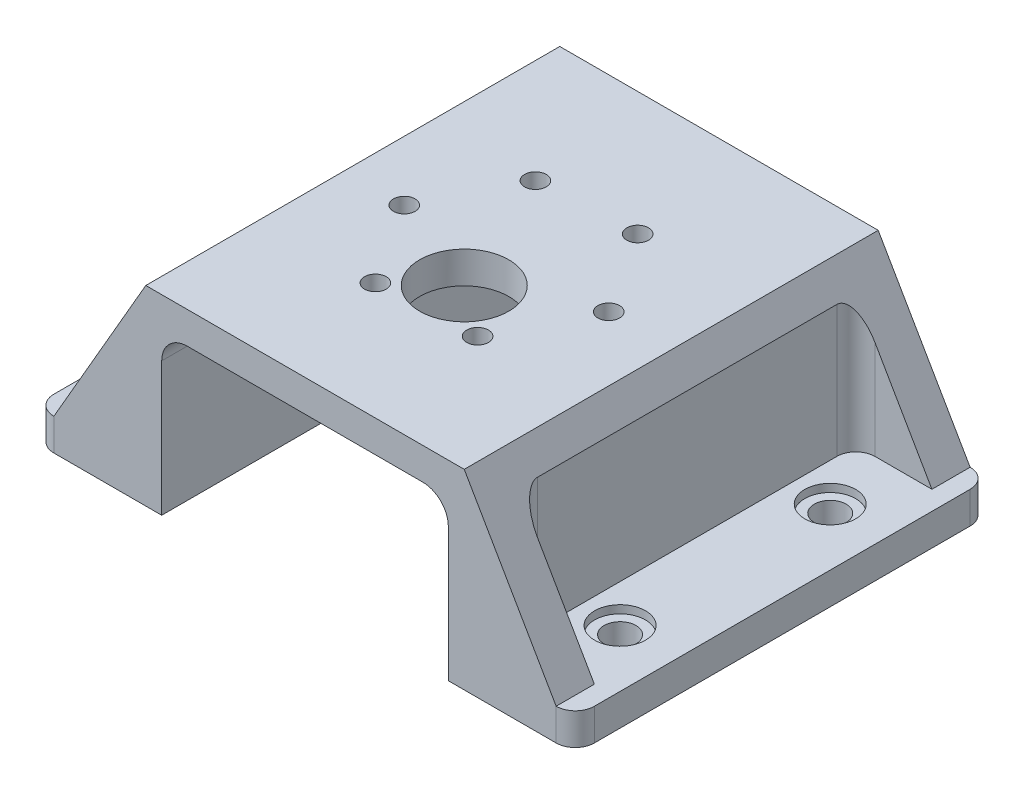
from build123d import *

# Parameters (mm, degrees)
SKETCH1_W           = 50
SKETCH1_H           = 50
BOSS_EXTRUDE1_DEPTH = 30
SKETCH2_R           = 7
CUT_EXTRUDE1_DEPTH  = 30
SKETCH3_R           = 1.7
CUT_EXTRUDE2_DEPTH  = 42
SKETCH5_W           = 50
SKETCH5_H           = 15
BOSS_EXTRUDE2_DEPTH = 30
BOSS_EXTRUDE3_DEPTH = 65
SKETCH7_W           = 45
SKETCH7_H           = 42.253035939
CUT_EXTRUDE3_DEPTH  = 66
FILLET1_R           = 4
CUT_EXTRUDE4_DEPTH  = 53
SKETCH10_R          = 4
CUT_EXTRUDE5_DEPTH  = 1.25
SKETCH11_R          = 2.5
CUT_EXTRUDE6_DEPTH  = 36.25
CUT_EXTRUDE7_DEPTH  = 90.25
FILLET2_R           = 3
SKETCH13_W          = 3
SKETCH13_H          = 5
BOSS_EXTRUDE4_DEPTH = 65
FILLET3_R           = 3


with BuildPart() as part:
    # Sketch1 → Boss-Extrude1 (new body)
    with BuildSketch(Plane(origin=(0, 0, 0), x_dir=(1, 0, 0), z_dir=(0, 1, 0))):
        Rectangle(SKETCH1_W, SKETCH1_H)
    extrude(amount=BOSS_EXTRUDE1_DEPTH)

    # Sketch2 → Cut-Extrude1 (cut)
    with BuildSketch(Plane(origin=(0, 30, 0), x_dir=(1, 0, 0), z_dir=(0, 1, 0))):
        Circle(SKETCH2_R)
    extrude(amount=-CUT_EXTRUDE1_DEPTH, mode=Mode.SUBTRACT)

    # Sketch3 → Cut-Extrude2 (cut)
    with BuildSketch(Plane.XZ):
        with Locations((6.617670641, -20.610654448)):
            Circle(SKETCH3_R)
        with Locations((14.927003033, -7.763670553)):
            Circle(SKETCH3_R)
        with Locations((7.955854814, 5.855914334)):
            Circle(SKETCH3_R)
        with Locations((-7.324625797, 6.628515327)):
            Circle(SKETCH3_R)
        with Locations((-15.633958189, -6.218468568)):
            Circle(SKETCH3_R)
        with Locations((-8.66280997, -19.838053456)):
            Circle(SKETCH3_R)
    extrude(amount=-CUT_EXTRUDE2_DEPTH, mode=Mode.SUBTRACT)

    # Sketch5 → Boss-Extrude2 (add)
    with BuildSketch(Plane(origin=(0, 30, 0), x_dir=(1, 0, 0), z_dir=(0, 1, 0))):
        with Locations((0, 32.5)):
            Rectangle(SKETCH5_W, SKETCH5_H)
    extrude(amount=-BOSS_EXTRUDE2_DEPTH)

    # Sketch6 → Boss-Extrude3 (add)
    with BuildSketch(Plane.XY.offset(25)):
        Polygon((-25, 30), (-42.320508076, 0), (-25, 0), align=None)
    boss_extrude3 = extrude(amount=-BOSS_EXTRUDE3_DEPTH)

    # Mirror1: Boss-Extrude3 across plane
    add(boss_extrude3.mirror(Plane(origin=(0, 0, 0), x_dir=(0, 0, 1), z_dir=(1, 0, 0))))

    # Sketch7 → Cut-Extrude3 (cut)
    with BuildSketch(Plane.XY.offset(25)):
        with Locations((0, 3.87348203)):
            Rectangle(SKETCH7_W, SKETCH7_H)
    extrude(amount=-CUT_EXTRUDE3_DEPTH, mode=Mode.SUBTRACT)

    # Fillet1
    fillet1_edges = [part.edges().sort_by_distance(p)[0] for p in [
        (-22.5, 25, -7.5),
        (22.5, 25, -7.5),
    ]]
    fillet(fillet1_edges, radius=FILLET1_R)

    # Sketch9 → Cut-Extrude4 (cut)
    with BuildSketch(Plane.XY.offset(19)):
        Polygon((27.5, 25.669872981), (39.43375673, 5), (27.5, 5), align=None)
    cut_extrude4 = extrude(amount=-CUT_EXTRUDE4_DEPTH, mode=Mode.SUBTRACT)

    # Mirror2: Cut-Extrude4 across plane
    add(cut_extrude4.mirror(Plane(origin=(0, 0, 0), x_dir=(0, 0, 1), z_dir=(1, 0, 0))), mode=Mode.SUBTRACT)

    # Sketch10 → Cut-Extrude5 (cut)
    with BuildSketch(Plane(origin=(0, 5, 0), x_dir=(1, 0, 0), z_dir=(0, 1, 0))):
        with Locations((33.466878365, 24)):
            Circle(SKETCH10_R)
        with Locations((33.466878365, -9)):
            Circle(SKETCH10_R)
        with Locations((-33.466878365, -9)):
            Circle(SKETCH10_R)
        with Locations((-33.466878365, 24)):
            Circle(SKETCH10_R)
    extrude(amount=-CUT_EXTRUDE5_DEPTH, mode=Mode.SUBTRACT)

    # Sketch11 → Cut-Extrude6 (cut)
    with BuildSketch(Plane(origin=(0, 3.75, 0), x_dir=(1, 0, 0), z_dir=(0, 1, 0))):
        with Locations((33.466878365, 24)):
            Circle(SKETCH11_R)
        with Locations((33.466878365, -9)):
            Circle(SKETCH11_R)
        with Locations((-33.466878365, -9)):
            Circle(SKETCH11_R)
        with Locations((-33.466878365, 24)):
            Circle(SKETCH11_R)
    extrude(amount=-CUT_EXTRUDE6_DEPTH, mode=Mode.SUBTRACT)

    # Sketch12 → Cut-Extrude7 (cut)
    with BuildSketch(Plane.XY.offset(25)):
        Polygon((42.320508076, 0), (39.43375673, 5), (39.43375673, 0), align=None)
    cut_extrude7 = extrude(amount=-CUT_EXTRUDE7_DEPTH, mode=Mode.SUBTRACT)

    # Mirror3: Cut-Extrude7 across plane
    add(cut_extrude7.mirror(Plane(origin=(0, 0, 0), x_dir=(0, 0, 1), z_dir=(1, 0, 0))), mode=Mode.SUBTRACT)

    # Fillet2
    fillet2_edges = [part.edges().sort_by_distance(p)[0] for p in [
        (27.5, 15.334936491, 19),
        (27.5, 15.334936491, -34),
        (-27.5, 15.334936491, -34),
        (-27.5, 15.334936491, 19),
    ]]
    fillet(fillet2_edges, radius=FILLET2_R)

    # Sketch13 → Boss-Extrude4 (add)
    with BuildSketch(Plane.XY.offset(25)):
        with Locations((40.93375673, 2.5)):
            Rectangle(SKETCH13_W, SKETCH13_H)
    boss_extrude4 = extrude(amount=-BOSS_EXTRUDE4_DEPTH)

    # Mirror4: Boss-Extrude4 across plane
    add(boss_extrude4.mirror(Plane(origin=(0, 0, 0), x_dir=(0, 0, 1), z_dir=(1, 0, 0))))

    # Fillet3
    fillet3_edges = [part.edges().sort_by_distance(p)[0] for p in [
        (42.43375673, 2.5, -40),
        (42.43375673, 2.5, 25),
        (-42.43375673, 2.5, 25),
        (-42.43375673, 2.5, -40),
    ]]
    fillet(fillet3_edges, radius=FILLET3_R)


solid = part.part
